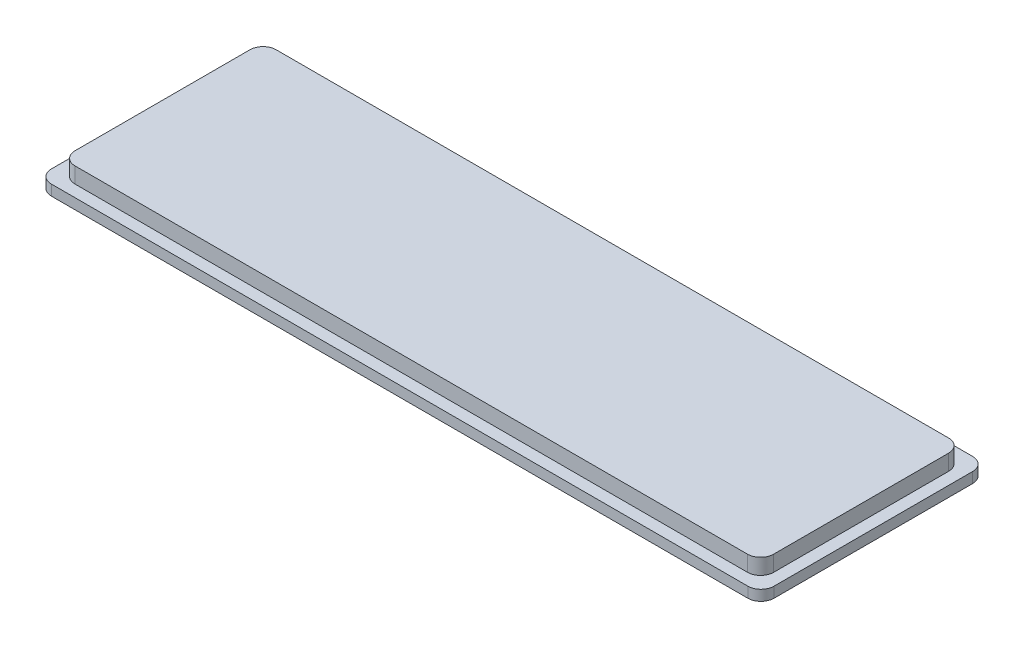
from build123d import *

# Parameters (mm, degrees)
SKETCH2_W           = 69.98716
SKETCH2_H           = 21.7678
BOSS_EXTRUDE1_DEPTH = 1.016
SKETCH3_W           = 67.6656
SKETCH3_H           = 19.4818
BOSS_EXTRUDE2_DEPTH = 1.524
FILLET1_R           = 1.27


with BuildPart() as part:
    # Sketch2 → Boss-Extrude1 (new body)
    with BuildSketch(Plane(origin=(0, 0, 0), x_dir=(1, 0, 0), z_dir=(0, 1, 0))):
        with Locations((34.99358, 10.8839)):
            Rectangle(SKETCH2_W, SKETCH2_H)
    extrude(amount=BOSS_EXTRUDE1_DEPTH)

    # Sketch3 → Boss-Extrude2 (add)
    with BuildSketch(Plane(origin=(0, 1.016, 0), x_dir=(1, 0, 0), z_dir=(0, 1, 0))):
        with Locations((34.9758, 10.8839)):
            Rectangle(SKETCH3_W, SKETCH3_H)
    extrude(amount=BOSS_EXTRUDE2_DEPTH)

    # Fillet1
    fillet1_edges = [part.edges().sort_by_distance(p)[0] for p in [
        (1.143, 1.778, -20.6248),
        (1.143, 1.778, -1.143),
        (68.8086, 1.778, -1.143),
        (68.8086, 1.778, -20.6248),
        (0, 0.508, -21.7678),
        (69.98716, 0.508, -21.7678),
        (69.98716, 0.508, 0),
        (0, 0.508, 0),
    ]]
    fillet(fillet1_edges, radius=FILLET1_R)


solid = part.part
